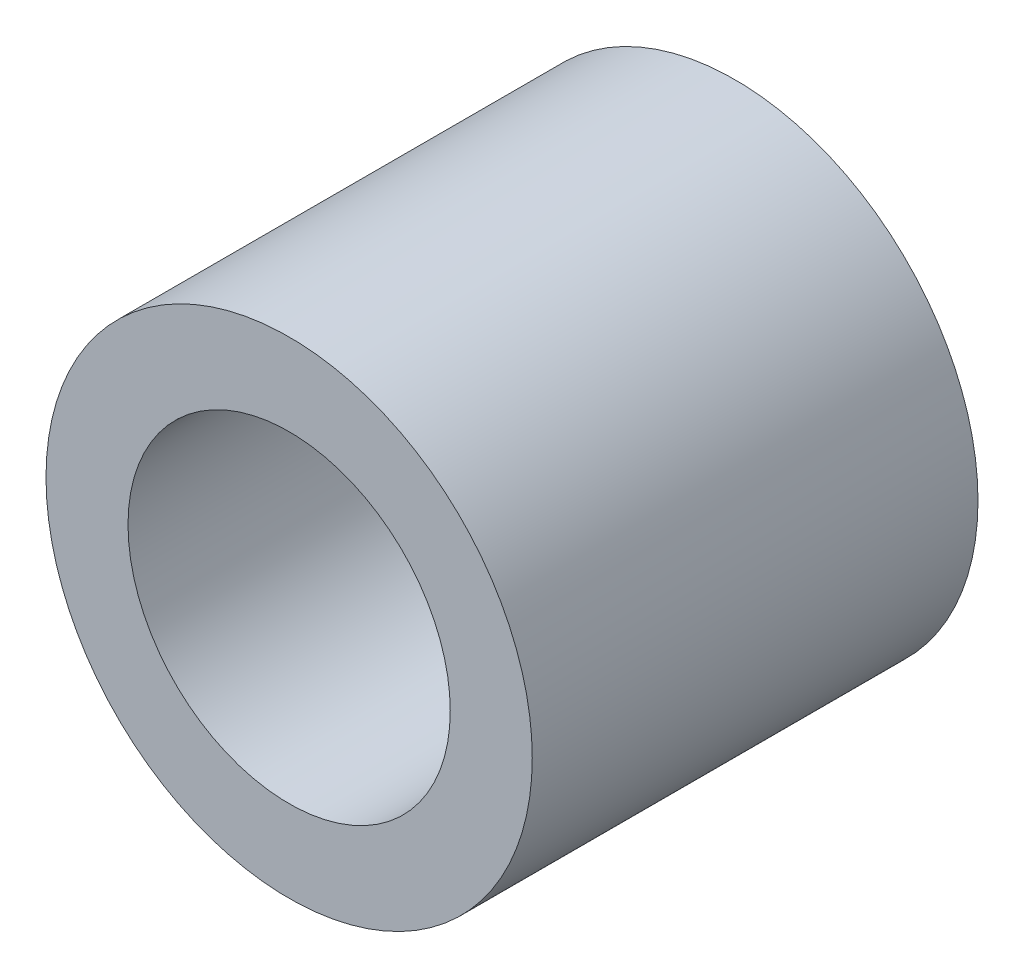
from build123d import *

# Parameters (mm, degrees)
SKETCH1_R           = 3.81
SKETCH1_R_2         = 2.525
BOSS_EXTRUDE1_DEPTH = 6.985


with BuildPart() as part:
    # Sketch1 → Boss-Extrude1 (new body)
    with BuildSketch(Plane.XY):
        Circle(SKETCH1_R)
        Circle(SKETCH1_R_2, mode=Mode.SUBTRACT)
    extrude(amount=BOSS_EXTRUDE1_DEPTH)


solid = part.part
